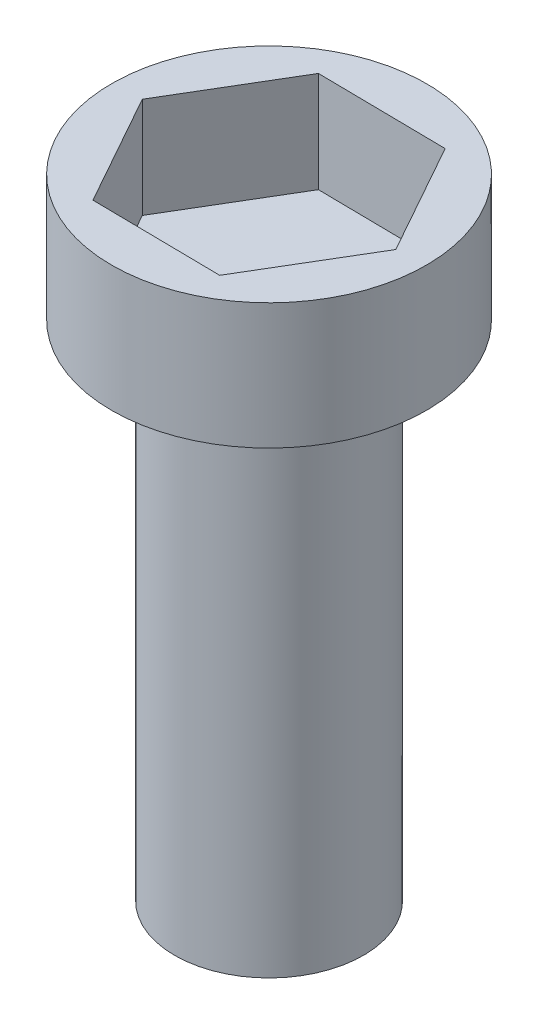
from build123d import *

# Parameters (mm, degrees)
SKETCH1_R           = 1.5
BOSS_EXTRUDE1_DEPTH = 8
SKETCH2_R           = 2.5
BOSS_EXTRUDE2_DEPTH = 2
CUT_EXTRUDE2_DEPTH  = 1.6


with BuildPart() as part:
    # Sketch1 → Boss-Extrude1 (new body)
    with BuildSketch(Plane(origin=(0, 0, 0), x_dir=(1, 0, 0), z_dir=(0, 1, 0))):
        Circle(SKETCH1_R)
    extrude(amount=BOSS_EXTRUDE1_DEPTH)

    # Sketch2 → Boss-Extrude2 (add)
    with BuildSketch(Plane(origin=(0, 8, 0), x_dir=(1, 0, 0), z_dir=(0, 1, 0))):
        Circle(SKETCH2_R)
    extrude(amount=BOSS_EXTRUDE2_DEPTH)

    # Sketch3 → Cut-Extrude2 (cut)
    with BuildSketch(Plane(origin=(0, 10, 0), x_dir=(1, 0, 0), z_dir=(0, 1, 0))):
        Polygon((0.997116077, -1.781560543), (2.041434727, -0.027252418), (1.04431865, 1.754308125), (-0.997116077, 1.781560543), (-2.041434727, 0.027252418), (-1.04431865, -1.754308125), align=None)
    extrude(amount=-CUT_EXTRUDE2_DEPTH, mode=Mode.SUBTRACT)


solid = part.part
